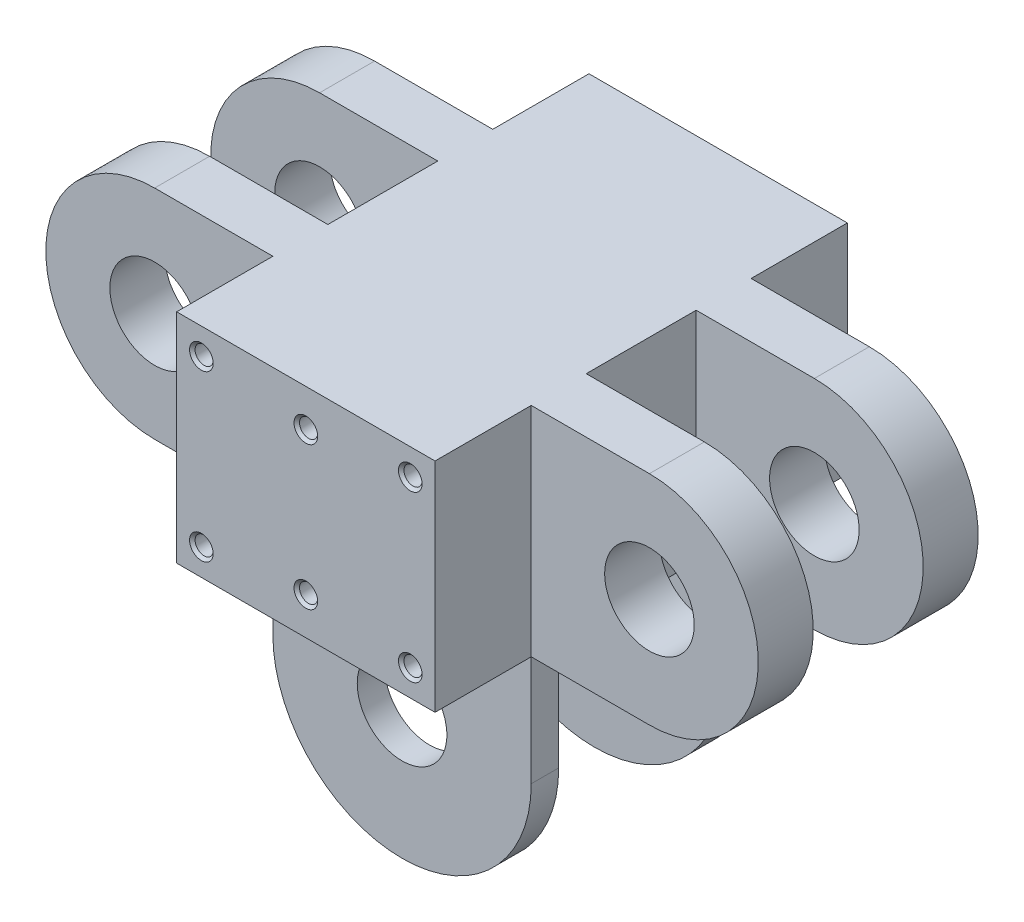
from build123d import *

# Parameters (mm, degrees)
SZKIC1_W                       = 47
SZKIC1_H                       = 39.6
DODANIE_WYCI_GNI_CIE3_DEPTH    = 75
SZKIC4_R                       = 8.15
DODANIE_WYCI_GNI_CIE4_DEPTH    = 10
SZKIC5_R                       = 8.15
DODANIE_WYCI_GNI_CIE5_DEPTH    = 5
OTW_R_GWINTOWANY_M4X0_71_D     = 3.3
OTW_R_GWINTOWANY_M4X0_71_DEPTH = 15
OTW_R_GWINTOWANY_M4X0_71_TIP   = 0.991420021
SFAZOWANIE1_SIZE               = 0.5


with BuildPart() as part:
    # Szkic1 → Dodanie-wyciągnięcie3 (new body)
    with BuildSketch(Plane.XY):
        with Locations((23.5, 19.8)):
            Rectangle(SZKIC1_W, SZKIC1_H)
    extrude(amount=DODANIE_WYCI_GNI_CIE3_DEPTH)

    # Szkic4 → Dodanie-wyciągnięcie4 (add)
    with BuildSketch(Plane(origin=(0, 0, 27.5), x_dir=(-1, 0, 0), z_dir=(0, 0, -1))):
        with BuildLine():
            Line((-47, 39.6), (-68.5, 39.6))
            ThreePointArc((-68.5, 39.6), (-88.3, 19.8), (-68.5, 0))
            Line((-68.5, 0), (-47, 0))
            Line((-47, 0), (-47, 39.6))
        make_face()
        with Locations((-68.5, 19.8)):
            Circle(SZKIC4_R, mode=Mode.SUBTRACT)
        with BuildLine():
            Line((21.5, 0), (0, 0))
            Line((0, 0), (0, 39.6))
            Line((0, 39.6), (21.5, 39.6))
            ThreePointArc((21.5, 39.6), (41.3, 19.8), (21.5, 0))
        make_face()
        with Locations((21.5, 19.8)):
            Circle(SZKIC4_R, mode=Mode.SUBTRACT)
    dodanie_wyci_gni_cie4 = extrude(amount=DODANIE_WYCI_GNI_CIE4_DEPTH)

    # Lustro1: Dodanie-wyciągnięcie4 across plane
    add(dodanie_wyci_gni_cie4.mirror(Plane(origin=(0, 0, 37.5), x_dir=(1, 0, 0), z_dir=(0, 0, -1))))

    # Szkic5 → Dodanie-wyciągnięcie5 (add)
    with BuildSketch(Plane(origin=(0, 0, 22.5), x_dir=(-1, 0, 0), z_dir=(0, 0, -1))):
        with BuildLine():
            Line((-47, 0), (0, 0))
            Line((0, 0), (0, -20))
            ThreePointArc((0, -20), (-23.5, -43.5), (-47, -20))
            Line((-47, -20), (-47, 0))
        make_face()
        with Locations((-23.5, -20)):
            Circle(SZKIC5_R, mode=Mode.SUBTRACT)
    dodanie_wyci_gni_cie5 = extrude(amount=DODANIE_WYCI_GNI_CIE5_DEPTH)

    # Lustro2: Dodanie-wyciągnięcie5 across plane
    add(dodanie_wyci_gni_cie5.mirror(Plane(origin=(0, 0, 37.5), x_dir=(1, 0, 0), z_dir=(0, 0, -1))))

    # Otwór gwintowany M4x0.71
    with Locations(Plane.XY.offset(75)):
        with Locations((4.5, 34.8), (23.5, 32.8), (42.5, 34.8), (42.5, 4.8), (23.5, 6.8), (4.5, 4.8)):
            Hole(OTW_R_GWINTOWANY_M4X0_71_D / 2, depth=OTW_R_GWINTOWANY_M4X0_71_DEPTH)
            with Locations((0, 0, -(OTW_R_GWINTOWANY_M4X0_71_DEPTH + OTW_R_GWINTOWANY_M4X0_71_TIP / 2))):  # 118° drill point
                Cone(0, OTW_R_GWINTOWANY_M4X0_71_D / 2, OTW_R_GWINTOWANY_M4X0_71_TIP, mode=Mode.SUBTRACT)

    # Sfazowanie1
    sfazowanie1_edges = [part.edges().sort_by_distance(p)[0] for p in [
        (6.15, 4.8, 75),
        (25.15, 6.8, 75),
        (44.15, 4.8, 75),
        (44.15, 34.8, 75),
        (25.15, 32.8, 75),
        (6.15, 34.8, 75),
    ]]
    chamfer(sfazowanie1_edges, length=SFAZOWANIE1_SIZE)


solid = part.part
